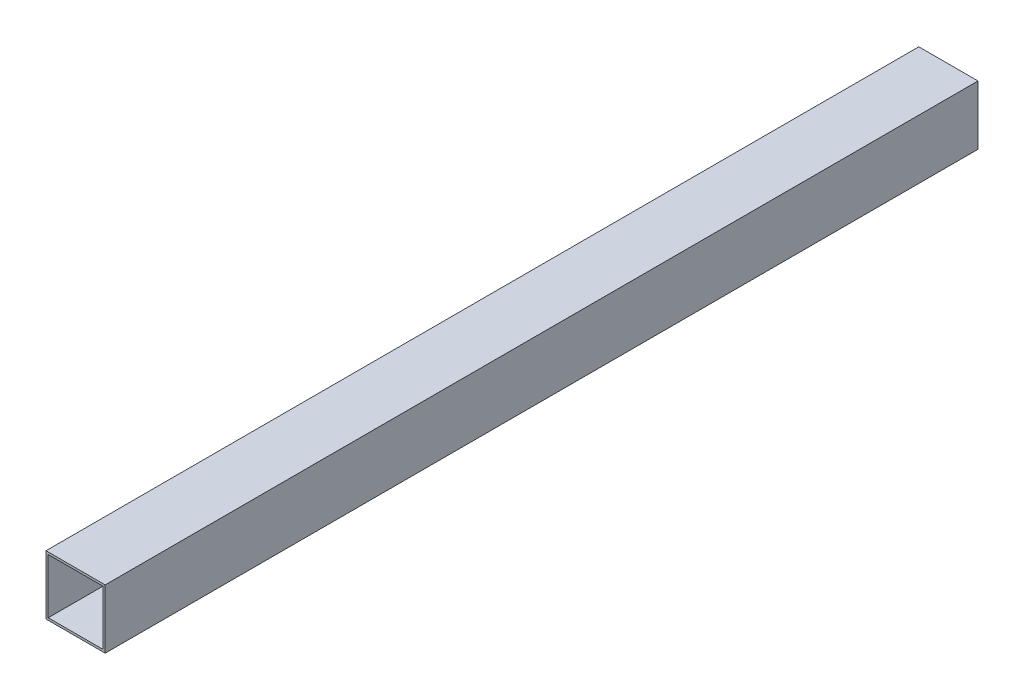
from build123d import *

# Parameters (mm, degrees)
ESBO_O1_W                = 40
ESBO_O1_H                = 40
RESSALTO_EXTRUS_O1_DEPTH = 590
ESBO_O2_W                = 37
ESBO_O2_H                = 37
CORTE_EXTRUS_O1_DEPTH    = 591


with BuildPart() as part:
    # Esboço1 → Ressalto-extrusão1 (new body)
    with BuildSketch(Plane.XY):
        Rectangle(ESBO_O1_W, ESBO_O1_H)
    extrude(amount=RESSALTO_EXTRUS_O1_DEPTH)

    # Esboço2 → Corte-extrusão1 (cut, through all)
    with BuildSketch(Plane.XY.offset(590)):
        Rectangle(ESBO_O2_W, ESBO_O2_H)
    extrude(amount=-CORTE_EXTRUS_O1_DEPTH, mode=Mode.SUBTRACT)


solid = part.part
